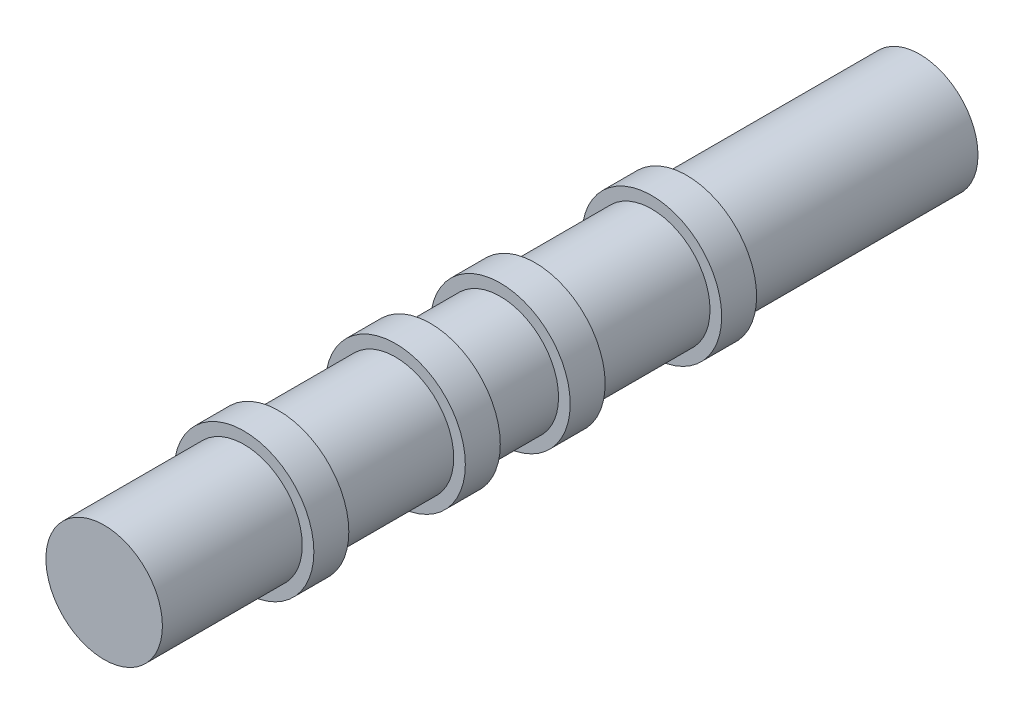
from build123d import *

# Parameters (mm, degrees)
SKETCH1_R           = 5
BOSS_EXTRUDE1_DEPTH = 20
SKETCH2_R           = 6
BOSS_EXTRUDE2_DEPTH = 3
SKETCH3_R           = 5
BOSS_EXTRUDE3_DEPTH = 10
SKETCH4_R           = 6
BOSS_EXTRUDE4_DEPTH = 3
SKETCH5_R           = 5
BOSS_EXTRUDE5_DEPTH = 6
SKETCH6_R           = 6
BOSS_EXTRUDE6_DEPTH = 3
SKETCH7_R           = 5
BOSS_EXTRUDE7_DEPTH = 10
SKETCH8_R           = 6
BOSS_EXTRUDE8_DEPTH = 3
SKETCH9_R           = 5
BOSS_EXTRUDE9_DEPTH = 12


with BuildPart() as part:
    # Sketch1 → Boss-Extrude1 (new body)
    with BuildSketch(Plane.XY):
        Circle(SKETCH1_R)
    extrude(amount=BOSS_EXTRUDE1_DEPTH)

    # Sketch2 → Boss-Extrude2 (add)
    with BuildSketch(Plane.XY.offset(20)):
        Circle(SKETCH2_R)
    extrude(amount=BOSS_EXTRUDE2_DEPTH)

    # Sketch3 → Boss-Extrude3 (add)
    with BuildSketch(Plane.XY.offset(23)):
        Circle(SKETCH3_R)
    extrude(amount=BOSS_EXTRUDE3_DEPTH)

    # Sketch4 → Boss-Extrude4 (add)
    with BuildSketch(Plane.XY.offset(33)):
        Circle(SKETCH4_R)
    extrude(amount=BOSS_EXTRUDE4_DEPTH)

    # Sketch5 → Boss-Extrude5 (add)
    with BuildSketch(Plane.XY.offset(36)):
        Circle(SKETCH5_R)
    extrude(amount=BOSS_EXTRUDE5_DEPTH)

    # Sketch6 → Boss-Extrude6 (add)
    with BuildSketch(Plane.XY.offset(42)):
        Circle(SKETCH6_R)
    extrude(amount=BOSS_EXTRUDE6_DEPTH)

    # Sketch7 → Boss-Extrude7 (add)
    with BuildSketch(Plane.XY.offset(45)):
        Circle(SKETCH7_R)
    extrude(amount=BOSS_EXTRUDE7_DEPTH)

    # Sketch8 → Boss-Extrude8 (add)
    with BuildSketch(Plane.XY.offset(55)):
        Circle(SKETCH8_R)
    extrude(amount=BOSS_EXTRUDE8_DEPTH)

    # Sketch9 → Boss-Extrude9 (add)
    with BuildSketch(Plane.XY.offset(58)):
        Circle(SKETCH9_R)
    extrude(amount=BOSS_EXTRUDE9_DEPTH)


solid = part.part
